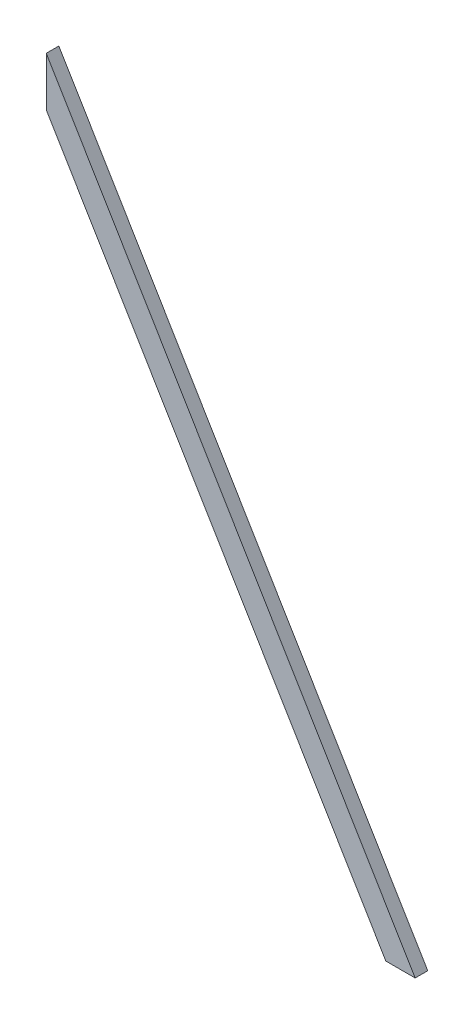
from build123d import *

# Parameters (mm, degrees)
BOSS_EXTRUDE1_DEPTH = 19.05


with BuildPart() as part:
    # Sketch1 → Boss-Extrude1 (new body)
    with BuildSketch(Plane.XY):
        Polygon((540.004, 0), (-18.796, 933.686763034), (-18.796, 859.496033764), (495.601764521, 0), align=None)
    extrude(amount=-BOSS_EXTRUDE1_DEPTH)


solid = part.part
